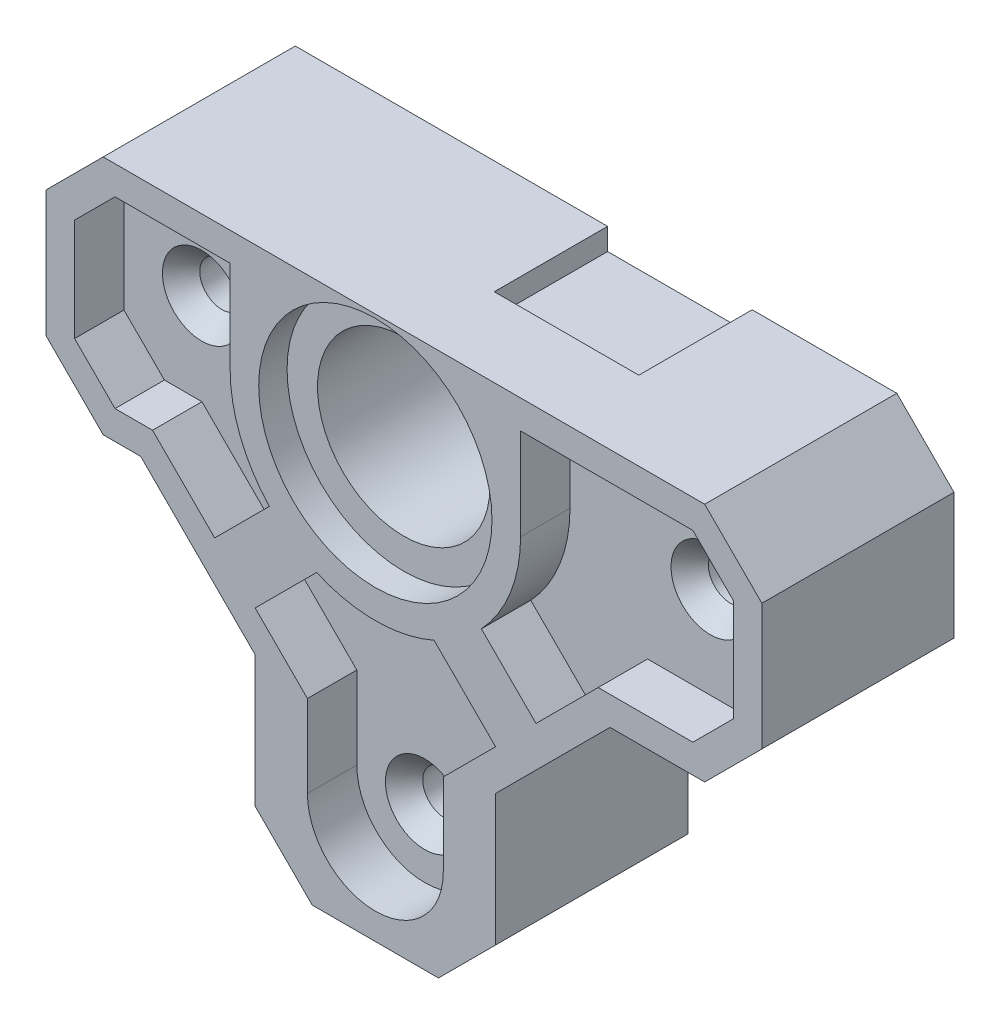
from build123d import *

# Parameters (mm, degrees)
BOSS_EXTRUDE1_DEPTH                           = 10.668
CSK_FOR_2_FLAT_HEAD_MACHINE_SCREW1_AT_2_COUNT = 2
CSK_FOR_2_FLAT_HEAD_MACHINE_SCREW1_AT_2_PITCH = 28.241625
CSK_FOR_2_FLAT_HEAD_MACHINE_SCREW1_AT_3_COUNT = 2
CSK_FOR_2_FLAT_HEAD_MACHINE_SCREW1_AT_3_PITCH = 24.18748446
SKETCH4_R                                     = 6.477
CUT_EXTRUDE1_DEPTH                            = 1.5748
SKETCH5_R                                     = 4.7879
CUT_EXTRUDE2_DEPTH                            = 11.668
SKETCH6_W                                     = 8.0264
SKETCH6_H                                     = 10.033
CUT_EXTRUDE3_DEPTH                            = 5.08
DRAFT2_ANGLE                                  = 45
CHAMFER1_SIZE                                 = 3.175
CHAMFER2_SIZE                                 = 6.35
CUT_EXTRUDE4_DEPTH                            = 2.7432


with BuildPart() as part:
    # Sketch1 → Boss-Extrude1 (new body)
    with BuildSketch(Plane.XY):
        Polygon((21.463, 6.6802), (-18.288, 6.6802), (-18.288, -6.6802), (-6.6802, -6.6802), (-6.6802, -23.495), (6.6802, -23.495), (6.6802, -6.6802), (21.463, -6.6802), align=None)
    extrude(amount=BOSS_EXTRUDE1_DEPTH)

    # Sketch3 → CSK for #2 Flat Head Machine Screw1 (revolve, cut)
    with BuildSketch(Plane(origin=(15.859125, 0, 10.668), x_dir=(0, -1, 0), z_dir=(1, 0, 0))):
        Polygon((0, 0), (0, 10.668), (1.2192, 10.668), (1.2192, 3.853535587), (2.1844, 2.7432), (2.1844, 0), align=None)
    csk_for_2_flat_head_machine_screw1 = revolve(axis=Axis((15.859125, 0, 17.018), (0, 0, -1)), mode=Mode.SUBTRACT)

    # CSK for #2 Flat Head Machine Screw1 at 2: CSK for #2 Flat Head Machine Screw1 ×2
    with Locations(*[(-i * CSK_FOR_2_FLAT_HEAD_MACHINE_SCREW1_AT_2_PITCH, 0, 0) for i in range(1, CSK_FOR_2_FLAT_HEAD_MACHINE_SCREW1_AT_2_COUNT)]):
        add(csk_for_2_flat_head_machine_screw1, mode=Mode.SUBTRACT)

    # CSK for #2 Flat Head Machine Screw1 at 3: CSK for #2 Flat Head Machine Screw1 ×2
    with Locations(*[Vector(-0.65567484, -0.755043379, 0) * (i * CSK_FOR_2_FLAT_HEAD_MACHINE_SCREW1_AT_3_PITCH) for i in range(1, CSK_FOR_2_FLAT_HEAD_MACHINE_SCREW1_AT_3_COUNT)]):
        add(csk_for_2_flat_head_machine_screw1, mode=Mode.SUBTRACT)

    # Sketch4 → Cut-Extrude1 (cut)
    with BuildSketch(Plane.XY.offset(10.668)):
        Circle(SKETCH4_R)
    extrude(amount=-CUT_EXTRUDE1_DEPTH, mode=Mode.SUBTRACT)

    # Sketch5 → Cut-Extrude2 (cut, through all)
    with BuildSketch(Plane.XY.offset(10.668)):
        Circle(SKETCH5_R)
    extrude(amount=-CUT_EXTRUDE2_DEPTH, mode=Mode.SUBTRACT)

    # Sketch6 → Cut-Extrude3 (cut)
    with BuildSketch(Plane(origin=(0, 0, 0), x_dir=(-1, 0, 0), z_dir=(0, 0, -1))):
        with Locations((-6.24205, 10.483214746)):
            Rectangle(SKETCH6_W, SKETCH6_H)
    extrude(amount=-CUT_EXTRUDE3_DEPTH, mode=Mode.SUBTRACT)

    # Draft2
    draft2_faces = [part.faces().sort_by_distance(p)[0] for p in [
        (6.24205, 6.073457373, 5.08),
    ]]
    draft(draft2_faces, Plane(origin=(10.25525, 5.466714746, 5.08), x_dir=(1, 0, 0), z_dir=(0, 1, 0)), DRAFT2_ANGLE)

    # Chamfer1
    chamfer1_edges = [part.edges().sort_by_distance(p)[0] for p in [
        (21.463, -6.6802, 5.334),
        (6.6802, -23.495, 5.334),
        (-6.6802, -23.495, 5.334),
        (-18.288, -6.6802, 5.334),
        (-18.288, 6.6802, 5.334),
        (21.463, 6.6802, 5.334),
    ]]
    chamfer(chamfer1_edges, length=CHAMFER1_SIZE)

    # Chamfer2
    chamfer2_edges = [part.edges().sort_by_distance(p)[0] for p in [
        (6.6802, -6.6802, 5.334),
        (-6.6802, -6.6802, 5.334),
    ]]
    chamfer(chamfer2_edges, length=CHAMFER2_SIZE)

    # Sketch7 → Cut-Extrude4 (cut)
    with BuildSketch(Plane.XY.offset(10.668)):
        with BuildLine():
            Line((3.7719, -13.69343597), (6.675135951, -10.790200019))
            Line((6.675135951, -10.790200019), (3.260798724, -7.375862792))
            ThreePointArc((3.260798724, -7.375862792), (0, -8.0645), (-3.260798724, -7.375862792))
            Line((-3.260798724, -7.375862792), (-6.675135951, -10.790200019))
            Line((-6.675135951, -10.790200019), (-3.7719, -13.69343597))
            Line((-3.7719, -13.69343597), (-3.7719, -18.2626))
            ThreePointArc((-3.7719, -18.2626), (0, -22.0345), (3.7719, -18.2626))
            Line((3.7719, -18.2626), (3.7719, -13.69343597))
        make_face()
        with BuildLine():
            Line((12.37263597, -5.0927), (17.63043597, -5.0927))
            Line((17.63043597, -5.0927), (19.8755, -2.84763597))
            Line((19.8755, -2.84763597), (19.8755, 2.84763597))
            Line((19.8755, 2.84763597), (17.63043597, 5.0927))
            Line((17.63043597, 5.0927), (8.0645, 5.0927))
            Line((8.0645, 5.0927), (8.0645, 0))
            ThreePointArc((8.0645, 0), (7.500371575, -2.963205441), (5.886910197, -5.511846205))
            Line((5.886910197, -5.511846205), (8.920199981, -8.545135989))
            Line((8.920199981, -8.545135989), (12.37263597, -5.0927))
        make_face()
        with BuildLine():
            Line((-14.45543597, 5.0927), (-16.7005, 2.84763597))
            Line((-16.7005, 2.84763597), (-16.7005, -2.84763597))
            Line((-16.7005, -2.84763597), (-14.45543597, -5.0927))
            Line((-14.45543597, -5.0927), (-12.37263597, -5.0927))
            Line((-12.37263597, -5.0927), (-8.920199981, -8.545135989))
            Line((-8.920199981, -8.545135989), (-5.886910197, -5.511846205))
            ThreePointArc((-5.886910197, -5.511846205), (-7.500371575, -2.963205441), (-8.0645, 0))
            Line((-8.0645, 0), (-8.0645, 5.0927))
            Line((-8.0645, 5.0927), (-14.45543597, 5.0927))
        make_face()
    extrude(amount=-CUT_EXTRUDE4_DEPTH, mode=Mode.SUBTRACT)


solid = part.part
